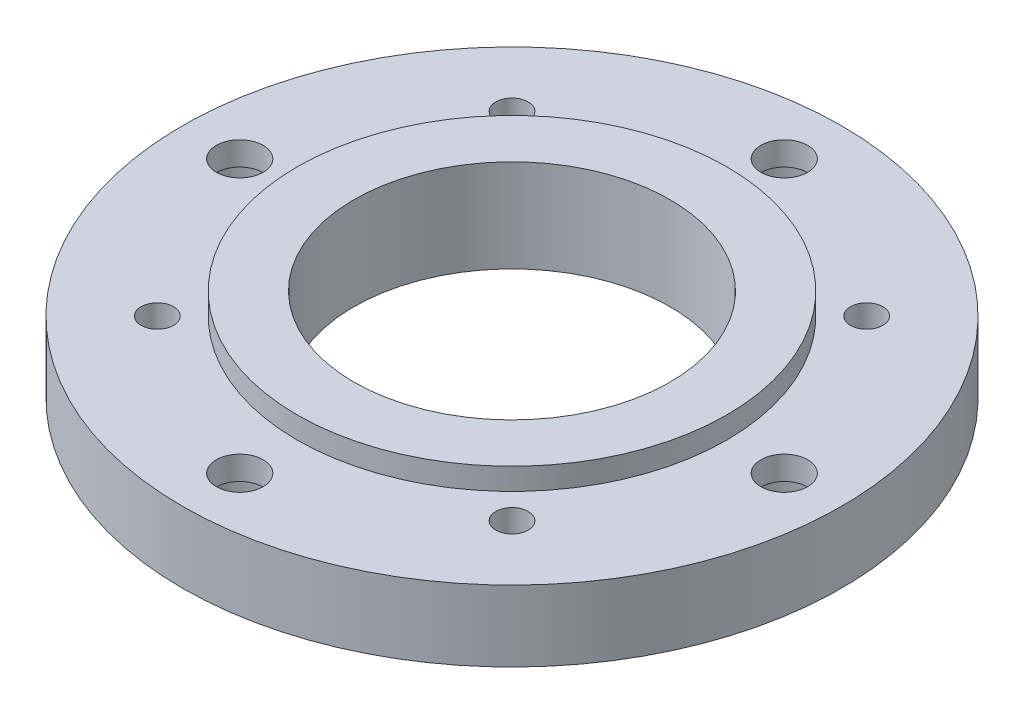
from build123d import *

# Parameters (mm, degrees)
SKETCH2_R                                      = 22.985
SKETCH2_R_2                                    = 1.63
SKETCH2_R_3                                    = 1.13
SKETCH2_R_4                                    = 14.985
SKETCH2_R_5                                    = 11.025
BOSS_EXTRUDE1_DEPTH                            = 4.95
BOSS_EXTRUDE2_START                            = 4.95
SKETCH2_3_R                                    = 14.985
SKETCH2_3_R_2                                  = 11.025
BOSS_EXTRUDE2_DEPTH                            = 1.52
F_4_40_TAPPED_HOLE1_D                          = 2.2606
CBORE_FOR_4_SOCKET_HEAD_CAP_SCREW1_D           = 3.2639
CBORE_FOR_4_SOCKET_HEAD_CAP_SCREW1_CBORE_D     = 6.450000054
CBORE_FOR_4_SOCKET_HEAD_CAP_SCREW1_CBORE_DEPTH = 3.300000004


with BuildPart() as part:
    # Sketch2 → Boss-Extrude1 (new body)
    with BuildSketch(Plane(origin=(0, 0, 0), x_dir=(1, 0, 0), z_dir=(0, 1, 0))):
        Circle(SKETCH2_R)
        with Locations((-18.99, 0)):
            Circle(SKETCH2_R_2, mode=Mode.SUBTRACT)
        with Locations((0, -18.99)):
            Circle(SKETCH2_R_2, mode=Mode.SUBTRACT)
        with Locations((18.99, 0)):
            Circle(SKETCH2_R_2, mode=Mode.SUBTRACT)
        with Locations((0, 18.99)):
            Circle(SKETCH2_R_2, mode=Mode.SUBTRACT)
        with Locations((12.367297603, -12.367297603)):
            Circle(SKETCH2_R_3, mode=Mode.SUBTRACT)
        with Locations((-12.367297603, -12.367297603)):
            Circle(SKETCH2_R_3, mode=Mode.SUBTRACT)
        with Locations((12.367297603, 12.367297603)):
            Circle(SKETCH2_R_3, mode=Mode.SUBTRACT)
        with Locations((-12.367297603, 12.367297603)):
            Circle(SKETCH2_R_3, mode=Mode.SUBTRACT)
        Circle(SKETCH2_R_4, mode=Mode.SUBTRACT)
        Circle(SKETCH2_R_4)
        Circle(SKETCH2_R_5, mode=Mode.SUBTRACT)
    extrude(amount=BOSS_EXTRUDE1_DEPTH)

    # Sketch2_3 → Boss-Extrude2 (add)
    with BuildSketch(Plane(origin=(0, 0, 0), x_dir=(1, 0, 0), z_dir=(0, 1, 0)).offset(BOSS_EXTRUDE2_START)):
        Circle(SKETCH2_3_R)
        Circle(SKETCH2_3_R_2, mode=Mode.SUBTRACT)
    extrude(amount=BOSS_EXTRUDE2_DEPTH)

    # 4-40 Tapped Hole1 (through all)
    with Locations(Plane(origin=(12.367297603, 4.95, -12.367297603), x_dir=(0, 0, 1), z_dir=(0, 1, 0))):
        with Locations((0, 0), (24.734595206, 0), (24.734595206, -24.734595206), (0, -24.734595206)):
            Hole(F_4_40_TAPPED_HOLE1_D / 2)

    # CBORE for _4 Socket Head Cap Screw1 (through all)
    with Locations(Plane(origin=(0, 0, 18.99), x_dir=(0, 0, -1), z_dir=(0, -1, 0))):
        with Locations((0, 0), (18.99, 18.99), (37.98, 0), (18.99, -18.99)):
            CounterBoreHole(CBORE_FOR_4_SOCKET_HEAD_CAP_SCREW1_D / 2, CBORE_FOR_4_SOCKET_HEAD_CAP_SCREW1_CBORE_D / 2, CBORE_FOR_4_SOCKET_HEAD_CAP_SCREW1_CBORE_DEPTH)


solid = part.part
